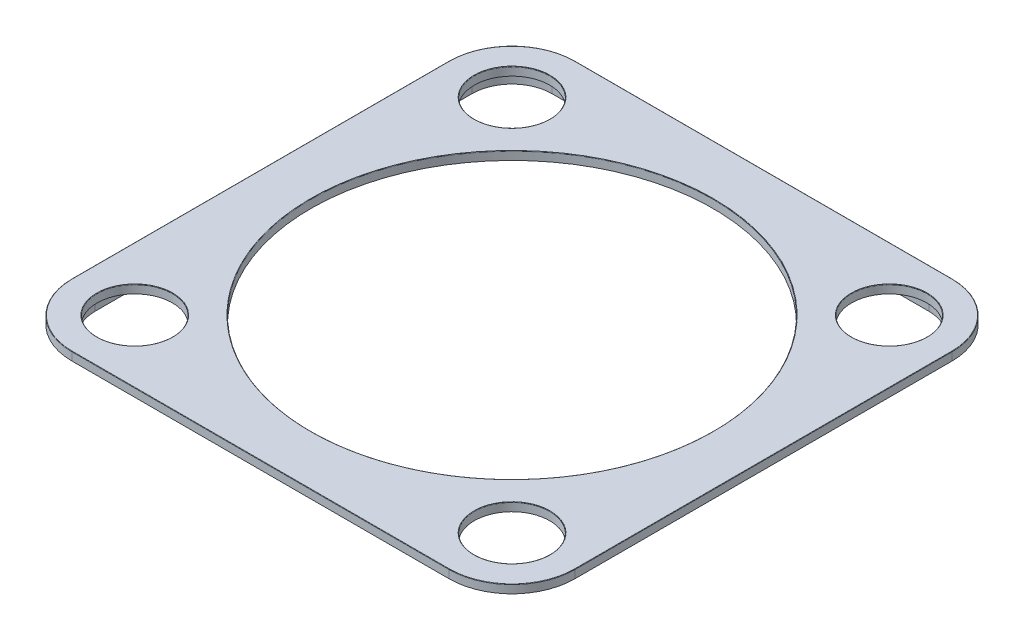
from build123d import *

# Parameters (mm, degrees)
BOSS_EXTRUDE1_DEPTH = 20
SKETCH3_R           = 90
CUT_EXTRUDE1_DEPTH  = 21
SKETCH4_R           = 480
CUT_EXTRUDE2_DEPTH  = 21
BOSS_EXTRUDE2_DEPTH = 20
FILLET1_R           = 1
FILLET2_R           = 1
FILLET3_R           = 1


with BuildPart() as part:
    # Sketch1 → Boss-Extrude1 (new body)
    with BuildSketch(Plane(origin=(0, 0, 0), x_dir=(1, 0, 0), z_dir=(0, 1, 0))):
        with BuildLine():
            Line((-450, -600), (450, -600))
            ThreePointArc((450, -600), (556.066017178, -556.066017178), (600, -450))
            Line((600, -450), (600, 450))
            ThreePointArc((600, 450), (556.066017178, 556.066017178), (450, 600))
            Line((450, 600), (-450, 600))
            ThreePointArc((-450, 600), (-556.066017178, 556.066017178), (-600, 450))
            Line((-600, 450), (-600, -450))
            ThreePointArc((-600, -450), (-556.066017178, -556.066017178), (-450, -600))
        make_face()
    extrude(amount=BOSS_EXTRUDE1_DEPTH)

    # Sketch3 → Cut-Extrude1 (cut, through all)
    with BuildSketch(Plane(origin=(0, 20, 0), x_dir=(1, 0, 0), z_dir=(0, 1, 0))):
        with Locations((-450, 450)):
            Circle(SKETCH3_R)
        with Locations((450, 450)):
            Circle(SKETCH3_R)
        with Locations((-450, -450)):
            Circle(SKETCH3_R)
        with Locations((450, -450)):
            Circle(SKETCH3_R)
    extrude(amount=-CUT_EXTRUDE1_DEPTH, mode=Mode.SUBTRACT)

    # Sketch4 → Cut-Extrude2 (cut, through all)
    with BuildSketch(Plane(origin=(0, 20, 0), x_dir=(1, 0, 0), z_dir=(0, 1, 0))):
        Circle(SKETCH4_R)
    extrude(amount=-CUT_EXTRUDE2_DEPTH, mode=Mode.SUBTRACT)

    # Sketch2 → Boss-Extrude2 (add)
    with BuildSketch(Plane.XZ):
        with BuildLine():
            Line((560, -450), (560, 450))
            ThreePointArc((560, 450), (527.781745931, 527.781745931), (450, 560))
            Line((450, 560), (-450, 560))
            ThreePointArc((-450, 560), (-527.781745931, 527.781745931), (-560, 450))
            Line((-560, 450), (-560, -450))
            ThreePointArc((-560, -450), (-527.781745931, -527.781745931), (-450, -560))
            Line((-450, -560), (450, -560))
            ThreePointArc((450, -560), (527.781745931, -527.781745931), (560, -450))
        make_face()
        with BuildLine():
            Line((545, -450), (545, 450))
            ThreePointArc((545, 450), (517.175144213, 517.175144213), (450, 545))
            Line((450, 545), (-450, 545))
            ThreePointArc((-450, 545), (-517.175144213, 517.175144213), (-545, 450))
            Line((-545, 450), (-545, -450))
            ThreePointArc((-545, -450), (-517.175144213, -517.175144213), (-450, -545))
            Line((-450, -545), (450, -545))
            ThreePointArc((450, -545), (517.175144213, -517.175144213), (545, -450))
        make_face(mode=Mode.SUBTRACT)
    extrude(amount=BOSS_EXTRUDE2_DEPTH)

    # Fillet1
    fillet1_edges = [part.edges().sort_by_distance(p)[0] for p in [
        (-556.066017178, 20, -556.066017178),
        (-600, 20, 0),
        (-556.066017178, 20, 556.066017178),
        (0, 20, 600),
        (556.066017178, 20, 556.066017178),
        (600, 20, 0),
        (556.066017178, 20, -556.066017178),
        (0, 20, -600),
    ]]
    fillet(fillet1_edges, radius=FILLET1_R)

    # Fillet2
    fillet2_edges = [part.edges().sort_by_distance(p)[0] for p in [
        (-480, 20, 0),
    ]]
    fillet(fillet2_edges, radius=FILLET2_R)

    # Fillet3
    fillet3_edges = [part.edges().sort_by_distance(p)[0] for p in [
        (-540, 20, -450),
        (360, 20, -450),
        (-540, 20, 450),
        (360, 20, 450),
    ]]
    fillet(fillet3_edges, radius=FILLET3_R)


solid = part.part
